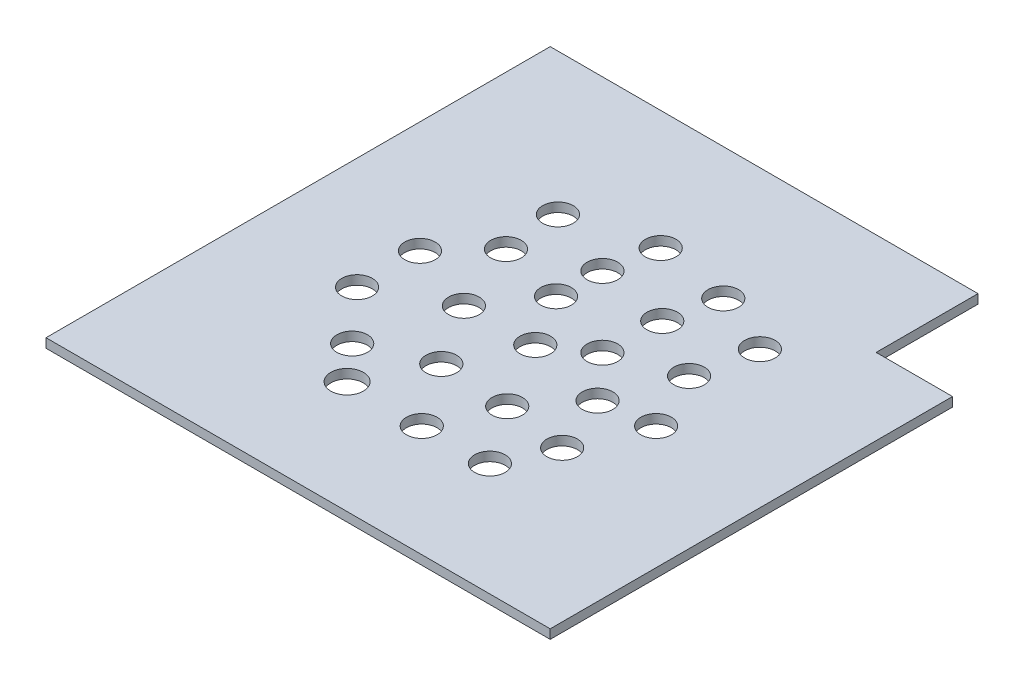
from build123d import *

# Parameters (mm, degrees)
SKETCH_1_W          = 99
SKETCH_1_H          = 99
EXTRUDE_1_DEPTH     = 1.8
SKETCH_2_R          = 3
SKETCH_2_R_2        = 3.197874374
CUT_EXTRUDE_1_DEPTH = 2.8
SKETCH_3_W          = 15
SKETCH_3_H          = 20
CUT_EXTRUDE_2_DEPTH = 2.8


with BuildPart() as part:
    # 草图1 → 凸台-拉伸1 (new body)
    with BuildSketch(Plane(origin=(0, 0, 0), x_dir=(1, 0, 0), z_dir=(0, 1, 0))):
        with Locations((49.5, 49.5)):
            Rectangle(SKETCH_1_W, SKETCH_1_H)
    extrude(amount=EXTRUDE_1_DEPTH)

    # 草图2 → 切除-拉伸1 (cut, through all)
    with BuildSketch(Plane(origin=(0, 1.8, 0), x_dir=(1, 0, 0), z_dir=(0, 1, 0))):
        with Locations((29.29818934, 71.224140528)):
            Circle(SKETCH_2_R)
        with Locations((45.102003727, 75.595349176)):
            Circle(SKETCH_2_R)
        with Locations((30.092218758, 60.228792633)):
            Circle(SKETCH_2_R)
        with Locations((35.605107574, 46.450435365)):
            Circle(SKETCH_2_R)
        with Locations((43.275213753, 34.342184277)):
            Circle(SKETCH_2_R)
        with Locations((56.937590385, 33.623111823)):
            Circle(SKETCH_2_R)
        with Locations((49.267484206, 46.806106819)):
            Circle(SKETCH_2_R)
        with Locations((64.847387383, 43.450435365)):
            Circle(SKETCH_2_R)
        with Locations((69.641203745, 56.633430361)):
            Circle(SKETCH_2_R)
        with Locations((57.65666284, 63.344773268)):
            Circle(SKETCH_2_R)
        with Locations((43.035522935, 57.112811997)):
            Circle(SKETCH_2_R)
        with Locations((43.275213753, 65.981372267)):
            Circle(SKETCH_2_R)
        with Locations((59.813880203, 73.172096811)):
            Circle(SKETCH_2_R)
        with Locations((69.401512927, 31.945276096)):
            Circle(SKETCH_2_R)
        with Locations((31.05098203, 29.068986279)):
            Circle(SKETCH_2_R)
        with Locations((51.904083205, 21.878261736)):
            Circle(SKETCH_2_R)
        with Locations((21.942730942, 39.13600064)):
            Circle(SKETCH_2_R)
        with Locations((21.942730942, 51.483942546)):
            Circle(SKETCH_2_R)
        with Locations((74.914401743, 44.888580274)):
            Circle(SKETCH_2_R)
        with Locations((64.98656548, 22.175939833)):
            Circle(SKETCH_2_R)
        with Locations((37.043252483, 22.07613611)):
            Circle(SKETCH_2_R_2)
        with Locations((72.038111926, 68.13858963)):
            Circle(SKETCH_2_R)
        with Locations((57.177281203, 52.079304817)):
            Circle(SKETCH_2_R)
    extrude(amount=-CUT_EXTRUDE_1_DEPTH, mode=Mode.SUBTRACT)

    # 草图3 → 切除-拉伸2 (cut, through all)
    with BuildSketch(Plane(origin=(0, 1.8, 0), x_dir=(1, 0, 0), z_dir=(0, 1, 0))):
        with Locations((91.5, 89)):
            Rectangle(SKETCH_3_W, SKETCH_3_H)
    extrude(amount=-CUT_EXTRUDE_2_DEPTH, mode=Mode.SUBTRACT)


solid = part.part
